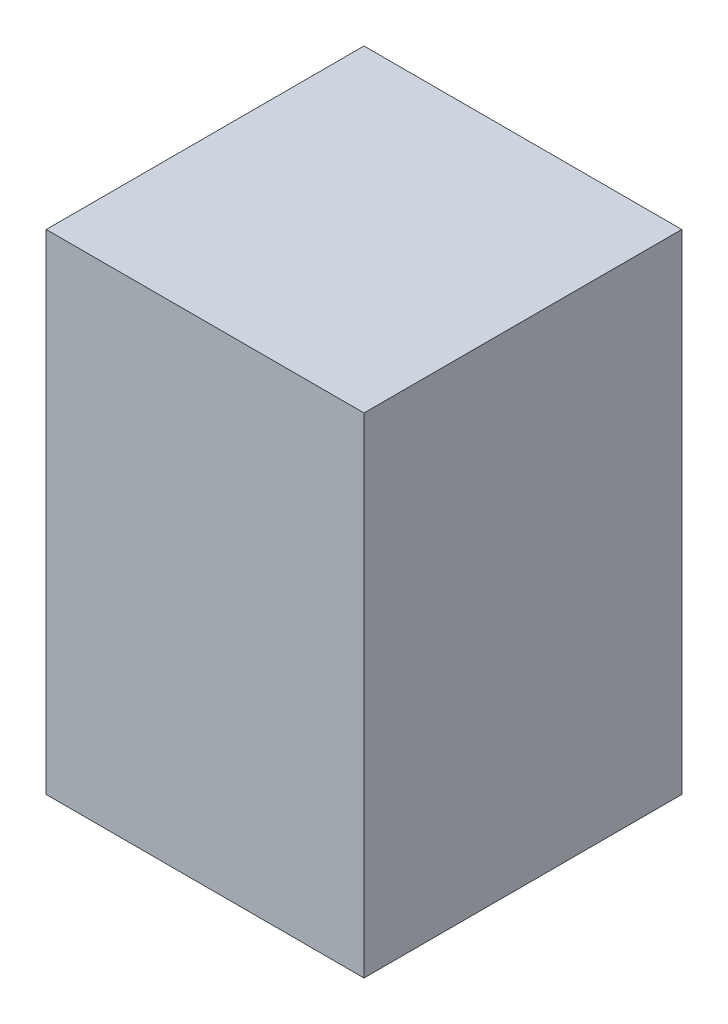
from build123d import *

# Parameters (mm, degrees)
CROQUIS1_W              = 500
CROQUIS1_H              = 500
SALIENTE_EXTRUIR1_DEPTH = 770


with BuildPart() as part:
    # Croquis1 → Saliente-Extruir1 (new body)
    with BuildSketch(Plane(origin=(0, 0, 0), x_dir=(1, 0, 0), z_dir=(0, 1, 0))):
        Rectangle(CROQUIS1_W, CROQUIS1_H)
    extrude(amount=SALIENTE_EXTRUIR1_DEPTH)


solid = part.part
